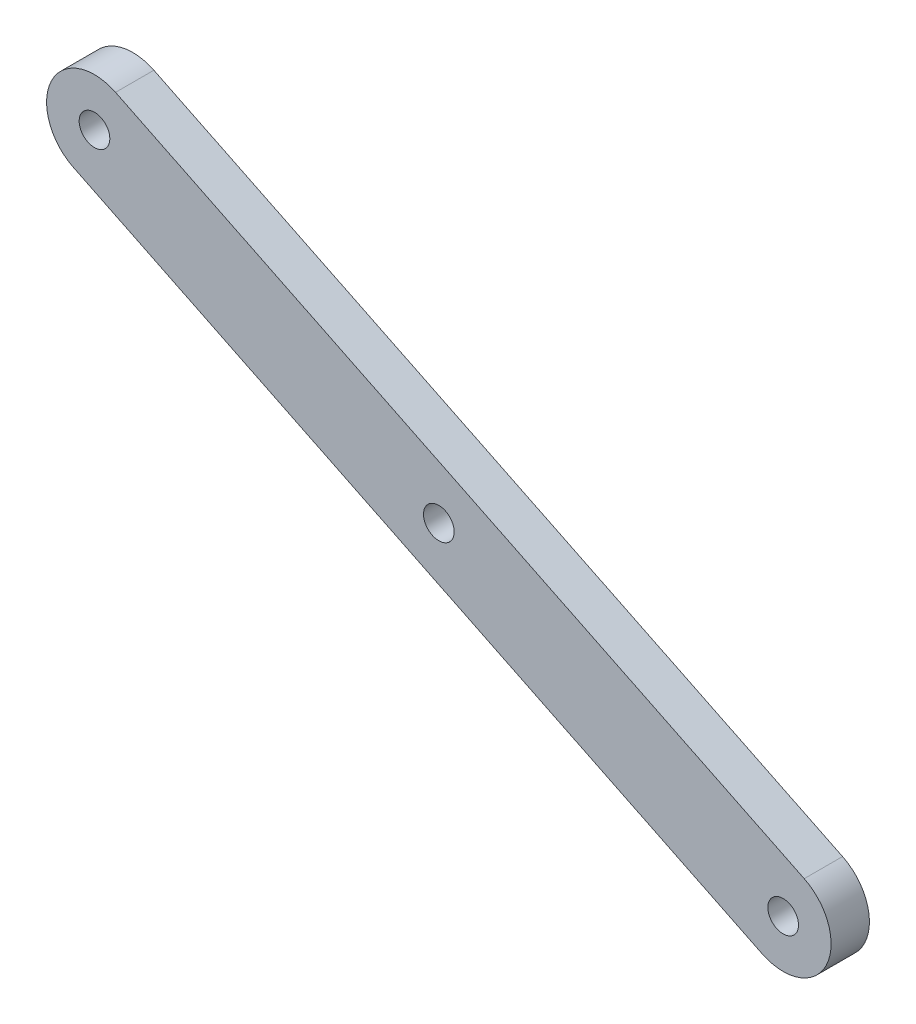
from build123d import *

# Parameters (mm, degrees)
SKETCH1_R           = 1.6
BOSS_EXTRUDE1_DEPTH = 4


with BuildPart() as part:
    # Sketch1 → Boss-Extrude1 (new body)
    with BuildSketch(Plane.XY):
        with BuildLine():
            Line((-2.195689363, -4.492098421), (-74.069264096, 30.638931382))
            ThreePointArc((-74.069264096, 30.638931382), (-76.365673155, 37.326719165), (-69.677885371, 39.623128223))
            Line((-69.677885371, 39.623128223), (2.195689363, 4.492098421))
            ThreePointArc((2.195689363, 4.492098421), (4.492098421, -2.195689363), (-2.195689363, -4.492098421))
        make_face()
        with Locations((-71.873574734, 35.131029803)):
            Circle(SKETCH1_R, mode=Mode.SUBTRACT)
        Circle(SKETCH1_R, mode=Mode.SUBTRACT)
        with Locations((-35.936787367, 17.565514901)):
            Circle(SKETCH1_R, mode=Mode.SUBTRACT)
    extrude(amount=BOSS_EXTRUDE1_DEPTH)


solid = part.part
